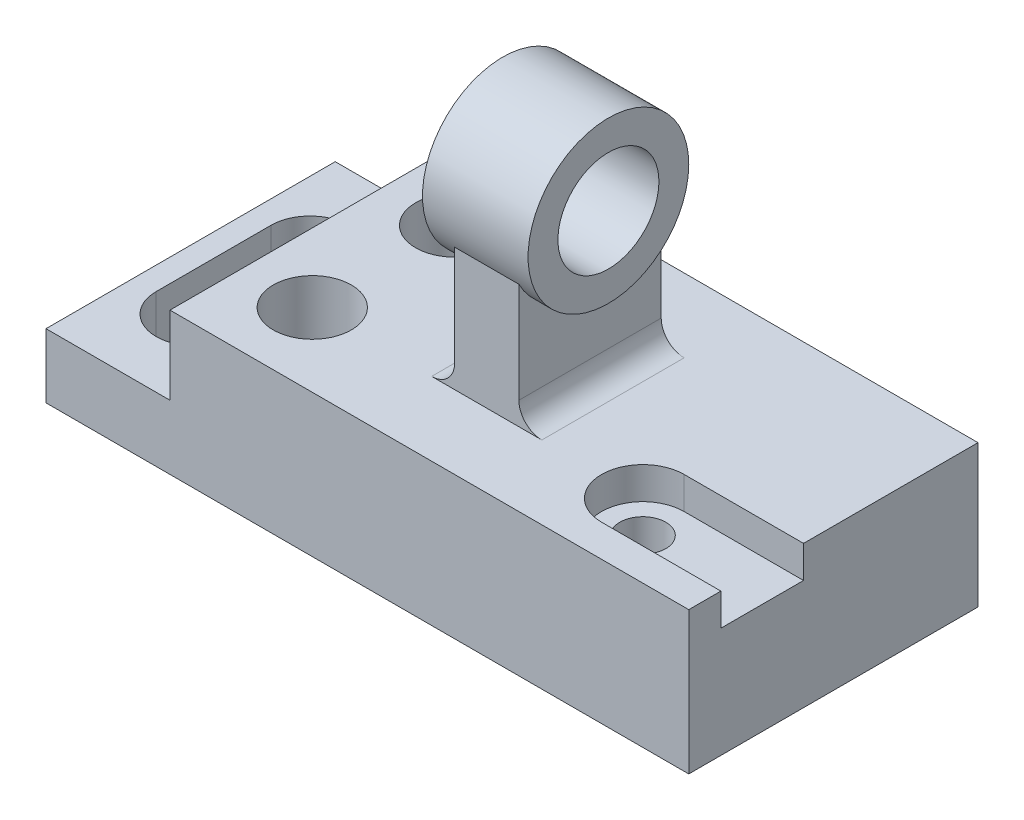
from build123d import *

# Parameters (mm, degrees)
BOSS_EXTRUDE1_DEPTH      = 31.5
SKETCH3_R                = 5
CUT_EXTRUDE1_DEPTH       = 86.336100216
SKETCH3_3_R              = 5
CUT_EXTRUDE2_DEPTH       = 7
SKETCH3_5_R              = 8.5
CUT_EXTRUDE3_DEPTH       = 86.336100216
CUT_EXTRUDE4_DEPTH       = 86.336100216
SKETCH4_R                = 12.5
CUT_EXTRUDE5_DEPTH       = 14
BOSS_EXTRUDE2_DEPTH      = 14
BOSS_EXTRUDE2_DEPTH_BACK = 9
SKETCH5_R                = 11
BOSS_EXTRUDE4_DEPTH      = 10
BOSS_EXTRUDE4_DEPTH_BACK = 4
FILLET1_R                = 5


with BuildPart() as part:
    # Sketch1 → Boss-Extrude1 (new, symmetric)
    with BuildSketch(Plane.XY):
        Polygon((-73, -31), (67, -31), (67, 0), (-46, 0), (-46, -17), (-73, -17), align=None)
    extrude(amount=BOSS_EXTRUDE1_DEPTH, both=True)

    # Sketch3 → Cut-Extrude1 (cut, through all)
    with BuildSketch(Plane(origin=(0, 0, 0), x_dir=(1, 0, 0), z_dir=(0, 1, 0))):
        with Locations((41, -15.5)):
            Circle(SKETCH3_R)
    extrude(amount=-CUT_EXTRUDE1_DEPTH, mode=Mode.SUBTRACT)

    # Sketch3_3 → Cut-Extrude2 (cut)
    with BuildSketch(Plane(origin=(0, 0, 0), x_dir=(1, 0, 0), z_dir=(0, 1, 0))):
        with BuildLine():
            Line((41, -24.5), (67, -24.5))
            Line((67, -24.5), (67, -6.5))
            Line((67, -6.5), (41, -6.5))
            ThreePointArc((41, -6.5), (32, -15.5), (41, -24.5))
        make_face()
        with Locations((41, -15.5)):
            Circle(SKETCH3_3_R, mode=Mode.SUBTRACT)
    extrude(amount=-CUT_EXTRUDE2_DEPTH, mode=Mode.SUBTRACT)

    # Sketch3_5 → Cut-Extrude3 (cut, through all)
    with BuildSketch(Plane(origin=(0, 0, 0), x_dir=(1, 0, 0), z_dir=(0, 1, 0))):
        with Locations((-31, 15.5)):
            Circle(SKETCH3_5_R)
        with Locations((-31, -15.5)):
            Circle(SKETCH3_5_R)
    extrude(amount=-CUT_EXTRUDE3_DEPTH, mode=Mode.SUBTRACT)

    # Sketch3_6 → Cut-Extrude4 (cut, through all)
    with BuildSketch(Plane(origin=(0, 0, 0), x_dir=(1, 0, 0), z_dir=(0, 1, 0))):
        with BuildLine():
            Line((-51, -12.5), (-51, 12.5))
            ThreePointArc((-51, 12.5), (-59.5, 21), (-68, 12.5))
            Line((-68, 12.5), (-68, -12.5))
            ThreePointArc((-68, -12.5), (-59.5, -21), (-51, -12.5))
        make_face()
    extrude(amount=-CUT_EXTRUDE4_DEPTH, mode=Mode.SUBTRACT)

    # Sketch4 → Cut-Extrude5 (cut)
    with BuildSketch(Plane.XZ.offset(31)):
        with Locations((-31, 15.5)):
            Circle(SKETCH4_R)
        with Locations((-31, -15.5)):
            Circle(SKETCH4_R)
    extrude(amount=-CUT_EXTRUDE5_DEPTH, mode=Mode.SUBTRACT)



with BuildPart() as body_2:
    # Sketch5 → Boss-Extrude2 (new, two sides: drawn at the far end of the back side and taken through both)
    with BuildSketch(Plane(origin=(4, 0, 0), x_dir=(0, 0, -1), z_dir=(1, 0, 0)).offset(-BOSS_EXTRUDE2_DEPTH_BACK)):
        with BuildLine():
            ThreePointArc((-15.5, 26.875961595), (0, 17.5), (15.5, 26.875961595))
            ThreePointArc((15.5, 26.875961595), (16.992645468, 30.816699867), (17.5, 35))
            ThreePointArc((17.5, 35), (-4.183300133, 51.992645468), (-15.5, 26.875961595))
        make_face()
        with Locations((0, 35)):
            Circle(SKETCH5_R, mode=Mode.SUBTRACT)
    extrude(amount=BOSS_EXTRUDE2_DEPTH + BOSS_EXTRUDE2_DEPTH_BACK)


with BuildPart() as part_1:
    add(part.part)

    add(body_2.part)  # Boss-Extrude4 merges body 2
    # Sketch5_6 → Boss-Extrude4 (add, two sides: drawn at the far end of the back side and taken through both)
    with BuildSketch(Plane(origin=(4, 0, 0), x_dir=(0, 0, -1), z_dir=(1, 0, 0)).offset(-BOSS_EXTRUDE4_DEPTH_BACK)):
        with BuildLine():
            Line((-15.5, 0), (15.5, 0))
            Line((15.5, 0), (15.5, 26.875961595))
            ThreePointArc((15.5, 26.875961595), (0, 17.5), (-15.5, 26.875961595))
            Line((-15.5, 26.875961595), (-15.5, 0))
        make_face()
    extrude(amount=BOSS_EXTRUDE4_DEPTH + BOSS_EXTRUDE4_DEPTH_BACK)

    # Fillet1
    fillet1_edges = [part_1.edges().sort_by_distance(p)[0] for p in [
        (14, 0, 0),
        (0, 0, 0),
    ]]
    fillet(fillet1_edges, radius=FILLET1_R)


solid = part_1.part
